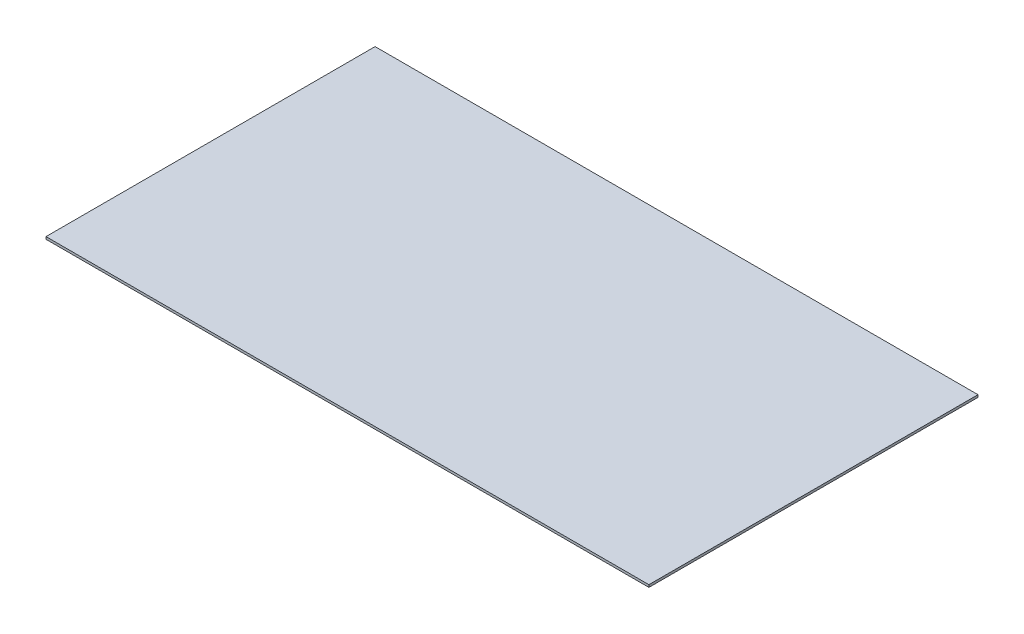
from build123d import *

# Parameters (mm, degrees)
SKETCH1_W           = 762
SKETCH1_H           = 415.925
BOSS_EXTRUDE1_DEPTH = 3


with BuildPart() as part:
    # Sketch1 → Boss-Extrude1 (new body)
    with BuildSketch(Plane(origin=(0, 0, 0), x_dir=(1, 0, 0), z_dir=(0, 1, 0))):
        with Locations((381, 207.9625)):
            Rectangle(SKETCH1_W, SKETCH1_H)
    extrude(amount=BOSS_EXTRUDE1_DEPTH)


solid = part.part
